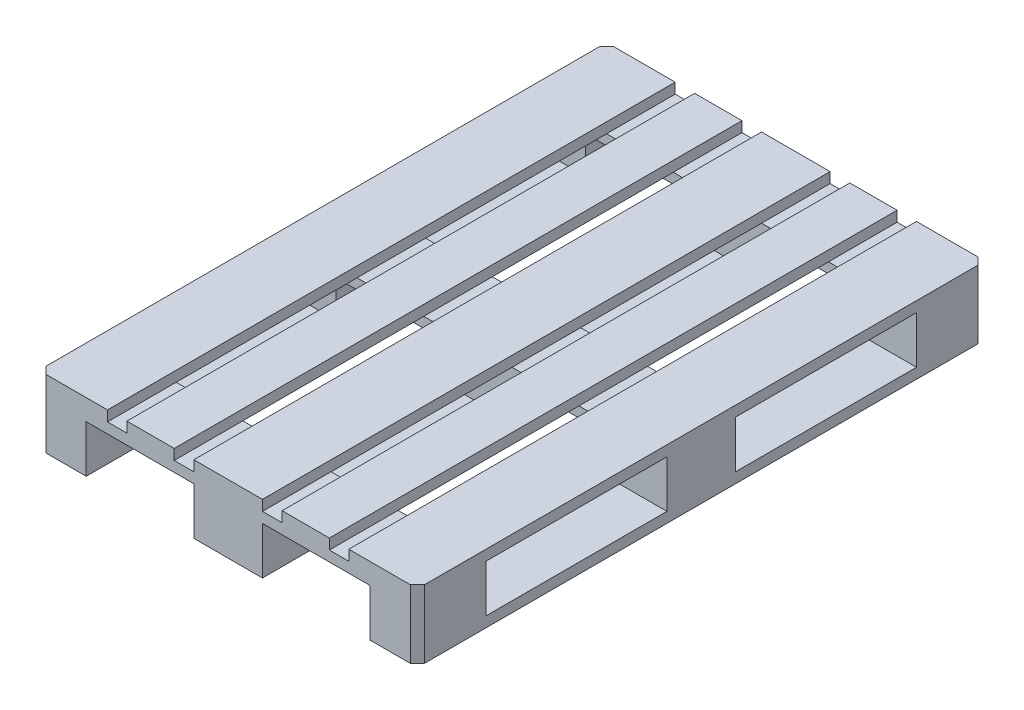
from build123d import *

# Parameters (mm, degrees)
SCHIZZO1_W                   = 60
SCHIZZO1_H                   = 7.2
SCHIZZO1_W_2                 = 19.125
SCHIZZO1_H_2                 = 5
ESTRUSIONE_ESTRUSIONE1_DEPTH = 40
SCHIZZO2_W                   = 11.375
SCHIZZO2_H                   = 5
SCHIZZO2_W_2                 = 2.075
SCHIZZO2_H_2                 = 1.1
SCHIZZO2_W_3                 = 2.05
TAGLIO_ESTRUSIONE1_DEPTH     = 61
SMUSSO1_SIZE                 = 0.75


with BuildPart() as part:
    # Schizzo1 → Estrusione-Estrusione1 (new body)
    with BuildSketch(Plane(origin=(0, 0, 0), x_dir=(0, 0, -1), z_dir=(1, 0, 0))):
        with Locations((30, 3.6)):
            Rectangle(SCHIZZO1_W, SCHIZZO1_H)
        with Locations((43.1875, 3.6)):
            Rectangle(SCHIZZO1_W_2, SCHIZZO1_H_2, mode=Mode.SUBTRACT)
        with Locations((16.8125, 3.6)):
            Rectangle(SCHIZZO1_W_2, SCHIZZO1_H_2, mode=Mode.SUBTRACT)
    extrude(amount=ESTRUSIONE_ESTRUSIONE1_DEPTH)

    # Schizzo2 → Taglio-Estrusione1 (cut, through all)
    with BuildSketch(Plane.XY):
        with Locations((10.6875, 2.5)):
            Rectangle(SCHIZZO2_W, SCHIZZO2_H)
        with Locations((29.3125, 2.5)):
            Rectangle(SCHIZZO2_W, SCHIZZO2_H)
        with Locations((15.3375, 6.65)):
            Rectangle(SCHIZZO2_W_2, SCHIZZO2_H_2)
        with Locations((8.275, 6.65)):
            Rectangle(SCHIZZO2_W_3, SCHIZZO2_H_2)
        with Locations((24.6625, 6.65)):
            Rectangle(SCHIZZO2_W_2, SCHIZZO2_H_2)
        with Locations((31.725, 6.65)):
            Rectangle(SCHIZZO2_W_3, SCHIZZO2_H_2)
    extrude(amount=-TAGLIO_ESTRUSIONE1_DEPTH, mode=Mode.SUBTRACT)

    # Smusso1
    smusso1_edges = [part.edges().sort_by_distance(p)[0] for p in [
        (40, 3.6, 0),
        (0, 3.6, 0),
        (0, 3.6, -60),
        (40, 3.6, -60),
    ]]
    chamfer(smusso1_edges, length=SMUSSO1_SIZE)


solid = part.part
